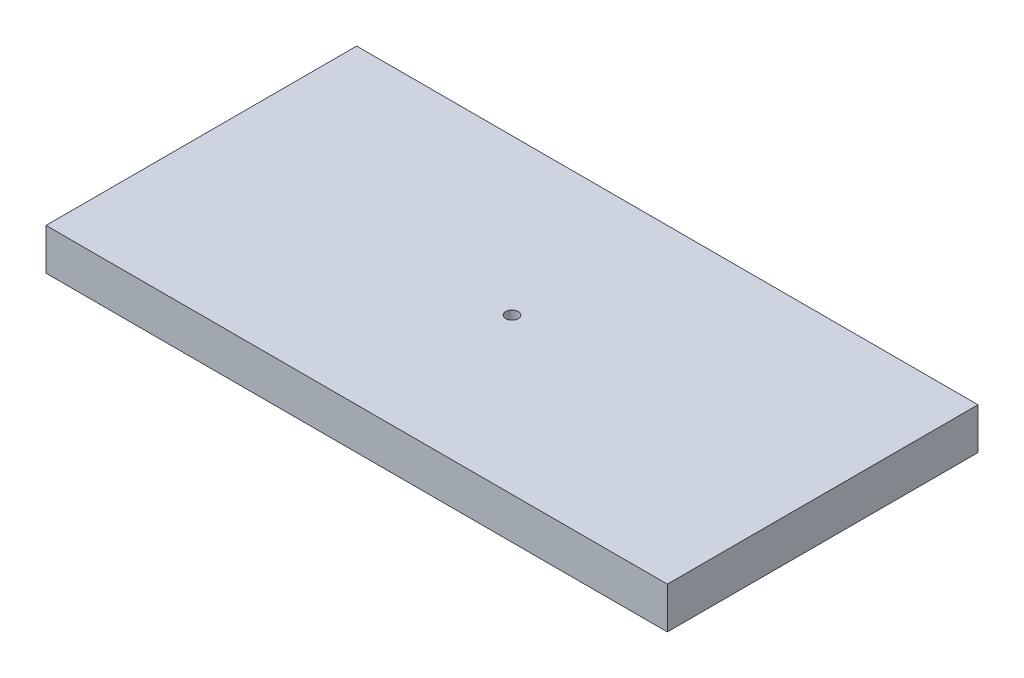
from build123d import *

# Parameters (mm, degrees)
SKETCH1_W           = 300
SKETCH1_H           = 150
BOSS_EXTRUDE1_DEPTH = 20
SKETCH2_R           = 3
CUT_EXTRUDE1_DEPTH  = 10


with BuildPart() as part:
    # Sketch1 → Boss-Extrude1 (new body)
    with BuildSketch(Plane(origin=(0, 0, 0), x_dir=(1, 0, 0), z_dir=(0, 1, 0))):
        Rectangle(SKETCH1_W, SKETCH1_H)
    extrude(amount=BOSS_EXTRUDE1_DEPTH)

    # Sketch2 → Cut-Extrude1 (cut)
    with BuildSketch(Plane(origin=(0, 20, 0), x_dir=(1, 0, 0), z_dir=(0, 1, 0))):
        Circle(SKETCH2_R)
    extrude(amount=-CUT_EXTRUDE1_DEPTH, mode=Mode.SUBTRACT)


solid = part.part
